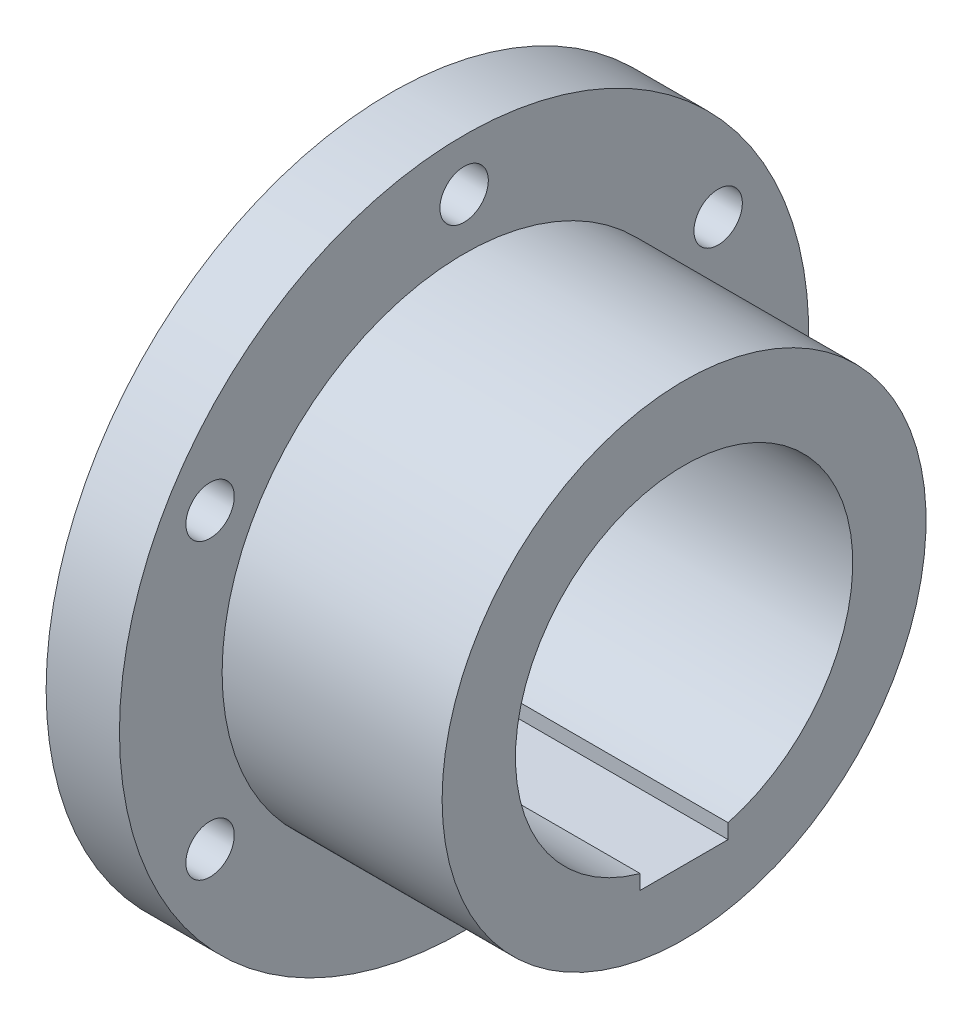
from build123d import *

# Parameters (mm, degrees)
SKETCH2_R          = 3.3
CUT_EXTRUDE1_DEPTH = 41
SKETCH3_W          = 12
SKETCH3_H          = 2
CUT_EXTRUDE2_DEPTH = 47


with BuildPart() as part:
    # Sketch1 → Revolve1 (revolve)
    with BuildSketch(Plane(origin=(0, 0, 0), x_dir=(1, 0, 0), z_dir=(0, 1, 0))):
        Polygon((0, 23), (46, 23), (46, 33), (16, 33), (16, 47), (6, 47), (6, 28), (0, 28), align=None)
    revolve(axis=Axis((-31.159383033, 0, 0), (1, 0, 0)))

    # Sketch2 → Cut-Extrude1 (cut, through all)
    with BuildSketch(Plane.ZY.offset(-6)):
        with Locations((0, 40)):
            Circle(SKETCH2_R)
        with Locations((34.641016151, 20)):
            Circle(SKETCH2_R)
        with Locations((34.641016151, -20)):
            Circle(SKETCH2_R)
        with Locations((0, -40)):
            Circle(SKETCH2_R)
        with Locations((-34.641016151, -20)):
            Circle(SKETCH2_R)
        with Locations((-34.641016151, 20)):
            Circle(SKETCH2_R)
    extrude(amount=-CUT_EXTRUDE1_DEPTH, mode=Mode.SUBTRACT)

    # Sketch3 → Cut-Extrude2 (cut, through all)
    with BuildSketch(Plane.ZY):
        with Locations((0, -23.203603311)):
            Rectangle(SKETCH3_W, SKETCH3_H)
    extrude(amount=-CUT_EXTRUDE2_DEPTH, mode=Mode.SUBTRACT)


solid = part.part
